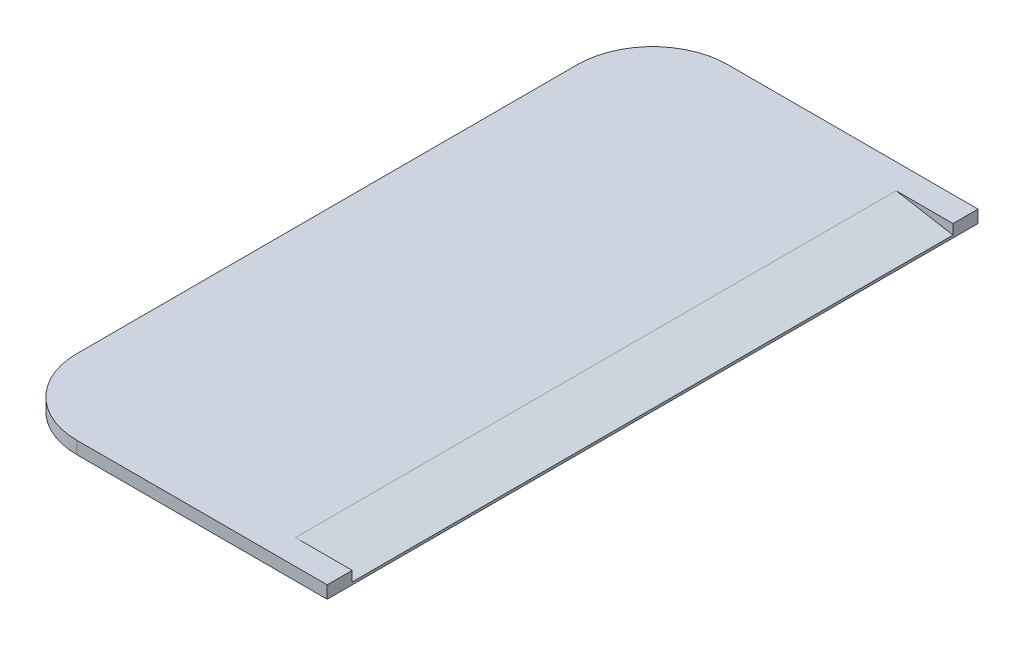
from build123d import *

# Parameters (mm, degrees)
BOSS_EXTRUDE1_DEPTH = 0.5
CUT_EXTRUDE4_DEPTH  = 24


with BuildPart() as part:
    # Sketch1 → Boss-Extrude1 (new body, symmetric)
    with BuildSketch(Plane(origin=(0, 0, 0), x_dir=(1, 0, 0), z_dir=(0, 1, 0))):
        with BuildLine():
            Line((-7, -26), (13, -26))
            Line((13, -26), (13, 26))
            Line((13, 26), (-7, 26))
            ThreePointArc((-7, 26), (-11.242640687, 24.242640687), (-13, 20))
            Line((-13, 20), (-13, -20))
            ThreePointArc((-13, -20), (-11.242640687, -24.242640687), (-7, -26))
        make_face()
    extrude(amount=BOSS_EXTRUDE1_DEPTH, both=True)

    # Sketch2 → Cut-Extrude4 (cut, symmetric)
    with BuildSketch(Plane.XY):
        Polygon((13, -0.3), (8.462974544, 0.5), (13, 0.5), align=None)
    extrude(amount=CUT_EXTRUDE4_DEPTH, both=True, mode=Mode.SUBTRACT)


solid = part.part
